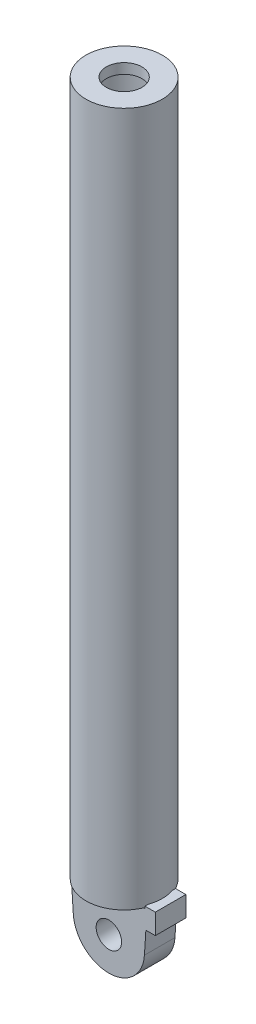
from build123d import *

# Parameters (mm, degrees)
SKETCH1_R           = 12.5
BOSS_EXTRUDE1_DEPTH = 15


with BuildPart() as part:
    # Sketch1 → Boss-Extrude1 (new body, symmetric)
    with BuildSketch(Plane.XY):
        with BuildLine():
            Line((37.628606884, 42), (35.5, 42))
            Line((35.5, 42), (35.5, 40))
            Line((35.5, 40), (-37.5, 40))
            Line((-37.5, 40), (-34.927862315, 0))
            ThreePointArc((-34.927862315, 0), (0, -32.754018227), (34.927862315, 0))
            Line((34.927862315, 0), (36.342538042, 22))
            Line((36.342538042, 22), (45.628606884, 22))
            Line((45.628606884, 22), (45.628606884, 42))
            Line((45.628606884, 42), (37.628606884, 42))
        make_face()
        Circle(SKETCH1_R, mode=Mode.SUBTRACT)
    extrude(amount=BOSS_EXTRUDE1_DEPTH, both=True)

    # Sketch2 → Revolve1 (revolve)
    with BuildSketch(Plane.XY):
        Polygon((-37.5, 722), (-17.5, 722), (-17.5, 712), (-32.5, 712), (-32.5, 172), (0, 172), (0, 40), (-37.5, 40), align=None)
    revolve(axis=Axis((0, 722, 0), (0, -1, 0)))


solid = part.part
